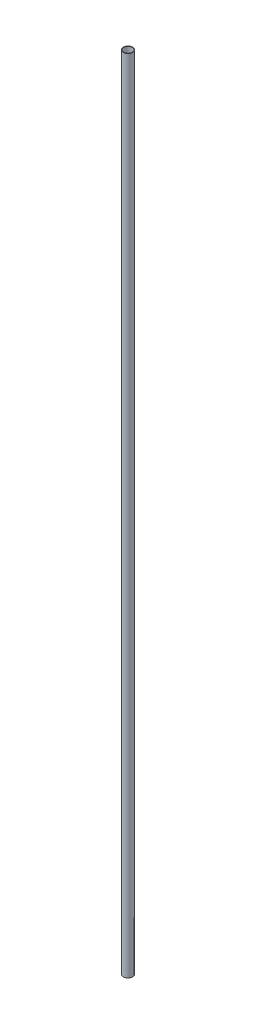
from build123d import *

# Parameters (mm, degrees)
SKETCH1_R           = 10.541
SKETCH1_R_2         = 9.525
BOSS_EXTRUDE1_DEPTH = 1803.4


with BuildPart() as part:
    # Sketch1 → Boss-Extrude1 (new body)
    with BuildSketch(Plane(origin=(0, 0, 0), x_dir=(1, 0, 0), z_dir=(0, 1, 0))):
        Circle(SKETCH1_R)
        Circle(SKETCH1_R_2, mode=Mode.SUBTRACT)
    extrude(amount=BOSS_EXTRUDE1_DEPTH)


solid = part.part
